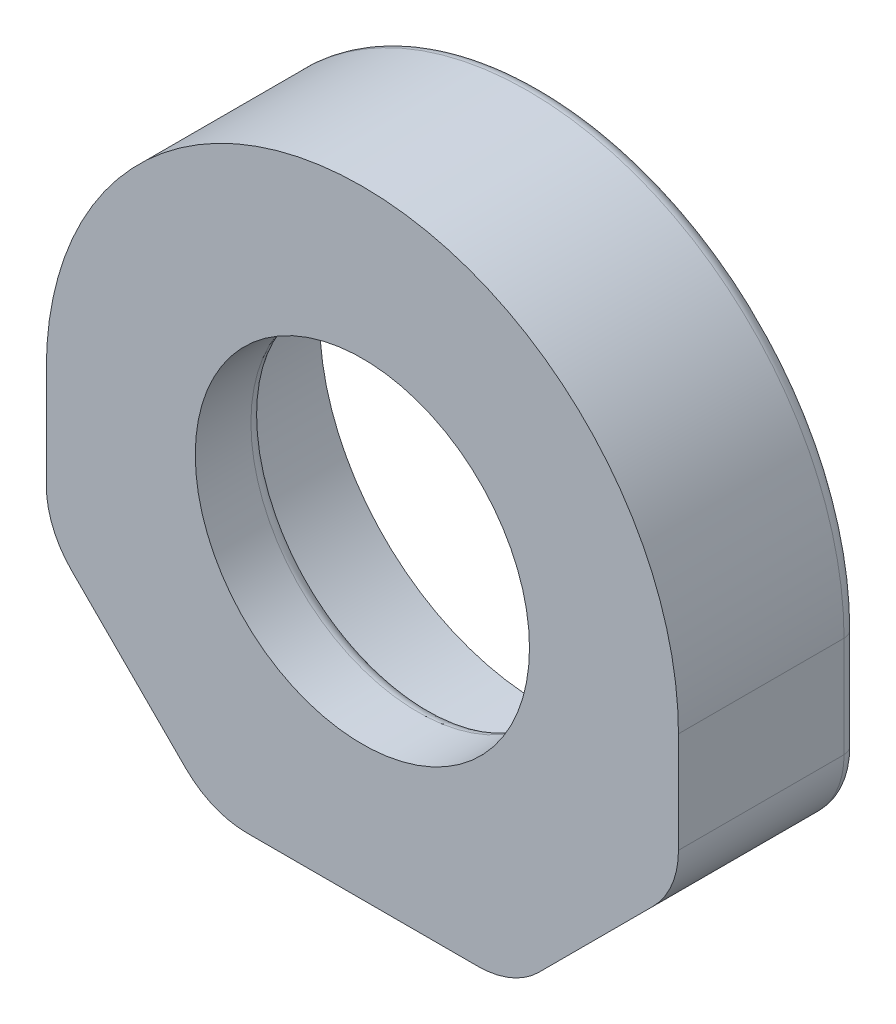
from build123d import *

# Parameters (mm, degrees)
BOSS_EXTRUDE1_DEPTH      = 63.5
BOSS_EXTRUDE1_DEPTH_BACK = 63.5
SKETCH3_R                = 36.5125
BOSS_EXTRUDE2_DEPTH      = 101.6
SKETCH4_R                = 19.304
CUT_EXTRUDE1_DEPTH       = 167.6875
SKETCH5_R                = 25.654
CUT_EXTRUDE2_DEPTH       = 12.7
CUT_EXTRUDE3_START       = -12.7
SKETCH6_R                = 25.654
CUT_EXTRUDE3_DEPTH       = 12.7
SKETCH7_R                = 30.4165
CUT_EXTRUDE4_DEPTH       = 78.834
CHAMFER1_SIZE            = 19.05
FILLET1_R                = 10
FILLET2_R                = 1.5875
CUT_EXTRUDE5_DEPTH       = 126.25163734
CUT_EXTRUDE5_DEPTH_BACK  = 126.25163734
SKETCH8_W                = 121.091569705
SKETCH8_H                = 140.894572221


with BuildPart() as part:
    # Sketch1 → Boss-Extrude1 (new, two sides: drawn at the far end of the back side and taken through both)
    with BuildSketch(Plane.XY.offset(-BOSS_EXTRUDE1_DEPTH_BACK)):
        with BuildLine():
            Line((-36.5125, 0), (-36.5125, -34.845102384))
            Line((-36.5125, -34.845102384), (36.5125, -34.845102384))
            Line((36.5125, -34.845102384), (36.5125, 0))
            ThreePointArc((36.5125, 0), (0, 36.5125), (-36.5125, 0))
        make_face()
    extrude(amount=BOSS_EXTRUDE1_DEPTH + BOSS_EXTRUDE1_DEPTH_BACK)

    # Sketch3 → Boss-Extrude2 (add)
    with BuildSketch(Plane(origin=(0, 0, 0), x_dir=(1, 0, 0), z_dir=(0, 1, 0))):
        Circle(SKETCH3_R)
    extrude(amount=BOSS_EXTRUDE2_DEPTH)

    # Sketch4 → Cut-Extrude1 (cut, through all)
    with BuildSketch(Plane(origin=(0, 0, -63.5), x_dir=(-1, 0, 0), z_dir=(0, 0, -1))):
        Circle(SKETCH4_R)
    extrude(amount=-CUT_EXTRUDE1_DEPTH, mode=Mode.SUBTRACT)

    # Sketch5 → Cut-Extrude2 (cut)
    with BuildSketch(Plane(origin=(0, 0, -63.5), x_dir=(-1, 0, 0), z_dir=(0, 0, -1))):
        Circle(SKETCH5_R)
    extrude(amount=-CUT_EXTRUDE2_DEPTH, mode=Mode.SUBTRACT)

    # Sketch6 → Cut-Extrude3 (cut)
    with BuildSketch(Plane.XY.offset(63.5).offset(CUT_EXTRUDE3_START)):
        Circle(SKETCH6_R)
    extrude(amount=CUT_EXTRUDE3_DEPTH, mode=Mode.SUBTRACT)

    # Sketch7 → Cut-Extrude4 (cut)
    with BuildSketch(Plane(origin=(0, 101.6, 0), x_dir=(1, 0, 0), z_dir=(0, 1, 0))):
        Circle(SKETCH7_R)
    extrude(amount=-CUT_EXTRUDE4_DEPTH, mode=Mode.SUBTRACT)

    # Chamfer1
    chamfer1_edges = [part.edges().sort_by_distance(p)[0] for p in [
        (36.5125, -34.845102384, 0),
        (-36.5125, -34.845102384, 0),
    ]]
    chamfer(chamfer1_edges, length=CHAMFER1_SIZE)

    # Fillet1
    fillet1_edges = [part.edges().sort_by_distance(p)[0] for p in [
        (36.5125, -15.795102384, 0),
        (17.4625, -34.845102384, 0),
        (-17.4625, -34.845102384, 0),
        (-36.5125, -15.795102384, 0),
    ]]
    fillet(fillet1_edges, radius=FILLET1_R)

    # Fillet2
    fillet2_edges = [part.edges().sort_by_distance(p)[0] for p in [
        (36.5125, -5.82648338, -63.5),
        (35.751295325, -15.479801084, -63.5),
        (26.9875, -25.320102384, -63.5),
        (17.1471987, -34.083897709, -63.5),
        (0, -34.845102384, -63.5),
        (-17.1471987, -34.083897709, -63.5),
        (-26.9875, -25.320102384, -63.5),
        (-35.751295325, -15.479801084, -63.5),
        (-36.5125, -5.82648338, -63.5),
        (36.5125, -5.82648338, 63.5),
        (35.751295325, -15.479801084, 63.5),
        (26.9875, -25.320102384, 63.5),
        (17.1471987, -34.083897709, 63.5),
        (0, -34.845102384, 63.5),
        (-17.1471987, -34.083897709, 63.5),
        (-26.9875, -25.320102384, 63.5),
        (-35.751295325, -15.479801084, 63.5),
        (-36.5125, -5.82648338, 63.5),
        (19.304, 0, -50.8),
        (19.304, 0, 50.8),
        (-30.4165, 101.6, 0),
        (-36.5125, 101.6, 0),
        (0, 36.5125, -63.5),
        (0, 36.5125, 63.5),
    ]]
    fillet(fillet2_edges, radius=FILLET2_R)

    # Sketch8 → Cut-Extrude5 (cut, two sides: drawn at the far end of the back side and taken through both)
    with BuildSketch(Plane(origin=(0, 0, 0), x_dir=(0, 0, -1), z_dir=(1, 0, 0)).offset(-CUT_EXTRUDE5_DEPTH_BACK)):
        with Locations((-17.762374118, 35.602183727)):
            Rectangle(SKETCH8_W, SKETCH8_H)
    extrude(amount=CUT_EXTRUDE5_DEPTH + CUT_EXTRUDE5_DEPTH_BACK, mode=Mode.SUBTRACT)


solid = part.part
